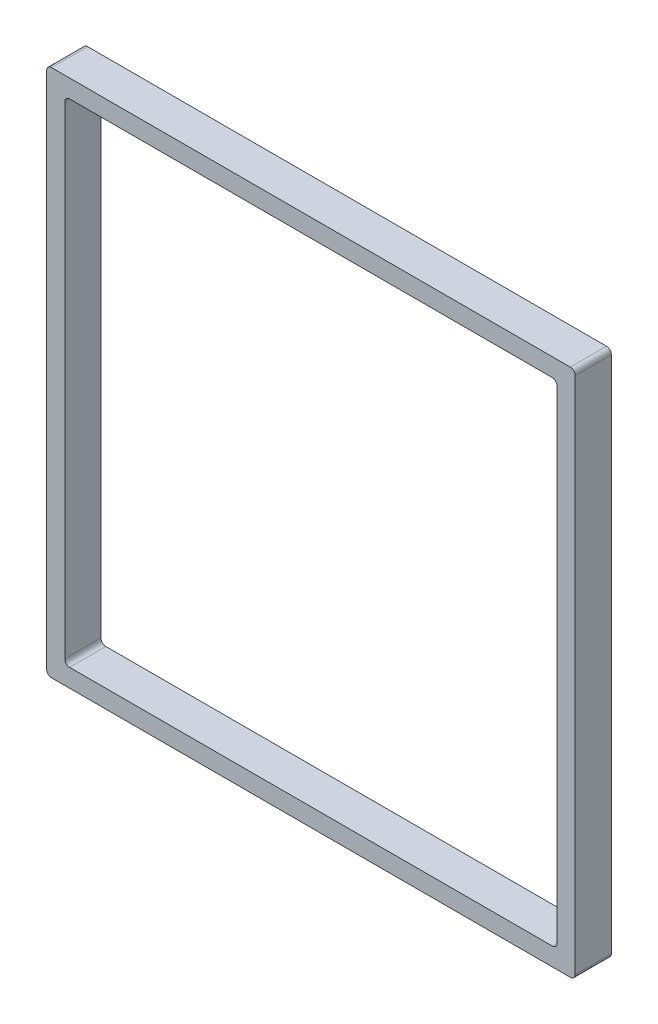
from build123d import *

# Parameters (mm, degrees)
SKETCH1_W           = 278.13
SKETCH1_H           = 278.13
SKETCH1_W_2         = 259.08
SKETCH1_H_2         = 259.08
BOSS_EXTRUDE1_DEPTH = 19.05
FILLET1_R           = 2.54


with BuildPart() as part:
    # Sketch1 → Boss-Extrude1 (new body)
    with BuildSketch(Plane.XY):
        Rectangle(SKETCH1_W, SKETCH1_H)
        Rectangle(SKETCH1_W_2, SKETCH1_H_2, mode=Mode.SUBTRACT)
    extrude(amount=BOSS_EXTRUDE1_DEPTH)

    # Fillet1
    fillet1_edges = [part.edges().sort_by_distance(p)[0] for p in [
        (129.54, -129.54, 9.525),
        (129.54, 129.54, 9.525),
        (-129.54, 129.54, 9.525),
        (-129.54, -129.54, 9.525),
        (139.065, -139.065, 9.525),
        (-139.065, -139.065, 9.525),
        (-139.065, 139.065, 9.525),
        (139.065, 139.065, 9.525),
    ]]
    fillet(fillet1_edges, radius=FILLET1_R)


solid = part.part
